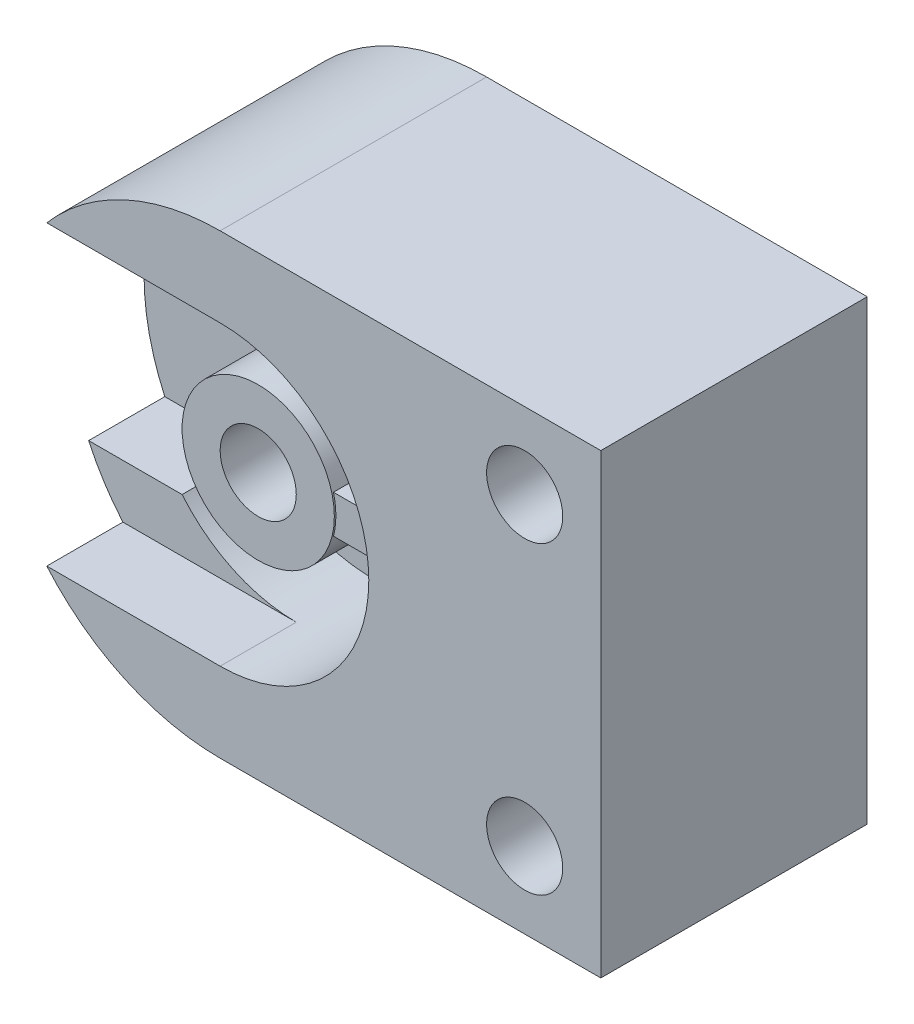
from build123d import *

# Parameters (mm, degrees)
SKETCH1_W                    = 160
SKETCH1_H                    = 120
BOSS_EXTRUDE1_DEPTH          = 70
CUT_EXTRUDE1_DEPTH           = 70
M20_TAPPED_HOLE3_D           = 17.5
M20_TAPPED_HOLE3_DEPTH       = 30
M20_TAPPED_HOLE3_CBORE_D     = 20
M20_TAPPED_HOLE3_CBORE_DEPTH = 25
M20_TAPPED_HOLE3_TIP         = 5.257530416
F_20_0MM_DOWEL_SLOT1_D       = 20
F_20_0MM_DOWEL_SLOT1_DEPTH   = 40
F_20_0MM_DOWEL_SLOT1_TIP     = 6.00860619
SKETCH16_R                   = 10
CUT_EXTRUDE3_DEPTH           = 40
CUT_EXTRUDE4_DEPTH           = 40
SKETCH18_R                   = 10
BOSS_EXTRUDE2_DEPTH          = 40
CUT_EXTRUDE6_DEPTH           = 20
SKETCH20_R                   = 10
CUT_EXTRUDE7_DEPTH           = 71
SKETCH21_R                   = 10
CUT_EXTRUDE8_DEPTH           = 20
CUT_EXTRUDE11_DEPTH          = 20
CUT_EXTRUDE12_DEPTH          = 20
SKETCH25_R                   = 20
SKETCH25_R_2                 = 10
BOSS_EXTRUDE6_DEPTH          = 10
RIB1_REACH                   = 186.662
SKETCH26_WALL_W              = 391.050063724
SKETCH26_WALL_H              = 10


with BuildPart() as part:
    # Sketch1 → Boss-Extrude1 (new body)
    with BuildSketch(Plane.XY):
        with Locations((80, 60)):
            Rectangle(SKETCH1_W, SKETCH1_H)
    extrude(amount=BOSS_EXTRUDE1_DEPTH)

    # Sketch2 → Cut-Extrude1 (cut)
    with BuildSketch(Plane.XY.offset(70)):
        with BuildLine():
            Line((60, 120), (0, 120))
            Line((0, 120), (0, 60))
            ThreePointArc((0, 60), (17.573593129, 102.426406871), (60, 120))
        make_face()
        with BuildLine():
            ThreePointArc((60, 0), (17.573593129, 17.573593129), (0, 60))
            Line((0, 60), (0, 0))
            Line((0, 0), (60, 0))
        make_face()
    extrude(amount=-CUT_EXTRUDE1_DEPTH, mode=Mode.SUBTRACT)

    # M20 Tapped Hole3
    with Locations(Plane(origin=(140, 100, 70), x_dir=(1, 0, 0), z_dir=(0, 0, 1))):
        with Locations((0, 0), (0, -80)):
            CounterBoreHole(M20_TAPPED_HOLE3_D / 2, M20_TAPPED_HOLE3_CBORE_D / 2, M20_TAPPED_HOLE3_CBORE_DEPTH, depth=M20_TAPPED_HOLE3_DEPTH)
            with Locations((0, 0, -(M20_TAPPED_HOLE3_DEPTH + M20_TAPPED_HOLE3_TIP / 2))):  # 118° drill point
                Cone(0, M20_TAPPED_HOLE3_D / 2, M20_TAPPED_HOLE3_TIP, mode=Mode.SUBTRACT)

    # 20.0mm Dowel Slot1
    with Locations(Plane.XY.offset(70)):
        with Locations((60, 60)):
            Hole(F_20_0MM_DOWEL_SLOT1_D / 2, depth=F_20_0MM_DOWEL_SLOT1_DEPTH)
            with Locations((0, 0, -(F_20_0MM_DOWEL_SLOT1_DEPTH + F_20_0MM_DOWEL_SLOT1_TIP / 2))):  # 118° drill point
                Cone(0, F_20_0MM_DOWEL_SLOT1_D / 2, F_20_0MM_DOWEL_SLOT1_TIP, mode=Mode.SUBTRACT)

    # Sketch16 → Cut-Extrude3 (cut)
    with BuildSketch(Plane.XY.offset(70)):
        with BuildLine():
            ThreePointArc((28.775010008, 35), (100, 60), (28.775010008, 85))
            Line((28.775010008, 85), (5.456439427, 85))
            ThreePointArc((5.456439427, 85), (0, 60), (5.456439427, 35))
            Line((5.456439427, 35), (28.775010008, 35))
        make_face()
        with Locations((60, 60)):
            Circle(SKETCH16_R, mode=Mode.SUBTRACT)
    extrude(amount=-CUT_EXTRUDE3_DEPTH, mode=Mode.SUBTRACT)

    # Sketch17 → Cut-Extrude4 (cut)
    with BuildSketch(Plane.XY.offset(30)):
        with BuildLine():
            Line((5.456439427, 85), (28.775010008, 85))
            ThreePointArc((28.775010008, 85), (42.679491924, 96.055512755), (60, 100))
            Line((60, 100), (15.27864045, 100))
            ThreePointArc((15.27864045, 100), (9.804072956, 92.868965731), (5.456439427, 85))
        make_face()
        with BuildLine():
            Line((28.775010008, 35), (5.456439427, 35))
            ThreePointArc((5.456439427, 35), (9.804072956, 27.131034269), (15.27864045, 20))
            Line((15.27864045, 20), (60, 20))
            ThreePointArc((60, 20), (42.679491924, 23.944487245), (28.775010008, 35))
        make_face()
    extrude(amount=CUT_EXTRUDE4_DEPTH, mode=Mode.SUBTRACT)

    # Sketch18 → Boss-Extrude2 (add)
    with BuildSketch(Plane.XY.offset(30)):
        with BuildLine():
            Line((60, 20), (15.27864045, 20))
            ThreePointArc((15.27864045, 20), (0, 60), (15.27864045, 100))
            Line((15.27864045, 100), (60, 100))
            ThreePointArc((60, 100), (100, 60), (60, 20))
        make_face()
        with Locations((60, 60)):
            Circle(SKETCH18_R, mode=Mode.SUBTRACT)
    extrude(amount=BOSS_EXTRUDE2_DEPTH)

    # Sketch19 → Cut-Extrude6 (cut)
    with BuildSketch(Plane(origin=(0, 0, 0), x_dir=(-1, 0, 0), z_dir=(0, 0, -1))):
        with BuildLine():
            ThreePointArc((-60, 99.05124838), (-43.43620227, 95.364397418), (-30, 85))
            Line((-30, 85), (-5.456439427, 85))
            ThreePointArc((-5.456439427, 85), (-9.461419592, 92.339633429), (-14.447832104, 99.05124838))
            Line((-14.447832104, 99.05124838), (-60, 99.05124838))
        make_face()
        with BuildLine():
            Line((-5.456439427, 85), (-30, 85))
            ThreePointArc((-30, 85), (-43.43620227, 95.364397418), (-60, 99.05124838))
            ThreePointArc((-60, 99.05124838), (-99.05124838, 60), (-60, 20.94875162))
            ThreePointArc((-60, 20.94875162), (-43.43620227, 24.635602582), (-30, 35))
            Line((-30, 35), (-5.456439427, 35))
            ThreePointArc((-5.456439427, 35), (0, 60), (-5.456439427, 85))
        make_face()
        with BuildLine():
            ThreePointArc((-14.447832104, 20.94875162), (-9.461419592, 27.660366571), (-5.456439427, 35))
            Line((-5.456439427, 35), (-30, 35))
            ThreePointArc((-30, 35), (-43.43620227, 24.635602582), (-60, 20.94875162))
            Line((-60, 20.94875162), (-14.447832104, 20.94875162))
        make_face()
    extrude(amount=-CUT_EXTRUDE6_DEPTH, mode=Mode.SUBTRACT)

    # Sketch20 → Cut-Extrude7 (cut)
    with BuildSketch(Plane.XY.offset(70)):
        with Locations(Location((60, 60, 0), (0, 0, 180))):
            Circle(SKETCH20_R)
    extrude(amount=-CUT_EXTRUDE7_DEPTH, mode=Mode.SUBTRACT)

    # Sketch21 → Cut-Extrude8 (cut)
    with BuildSketch(Plane.XY.offset(70)):
        with BuildLine():
            Line((30, 35), (5.456439427, 35))
            ThreePointArc((5.456439427, 35), (9.461419592, 27.660366571), (14.447832104, 20.94875162))
            Line((14.447832104, 20.94875162), (60, 20.94875162))
            ThreePointArc((60, 20.94875162), (43.43620227, 24.635602582), (30, 35))
        make_face()
        with BuildLine():
            Line((5.456439427, 85), (30, 85))
            ThreePointArc((30, 85), (43.43620227, 95.364397418), (60, 99.05124838))
            Line((60, 99.05124838), (14.447832104, 99.05124838))
            ThreePointArc((14.447832104, 99.05124838), (9.461419592, 92.339633429), (5.456439427, 85))
        make_face()
        with BuildLine():
            ThreePointArc((60, 99.05124838), (43.43620227, 95.364397418), (30, 85))
            Line((30, 85), (5.456439427, 85))
            ThreePointArc((5.456439427, 85), (0, 60), (5.456439427, 35))
            Line((5.456439427, 35), (30, 35))
            ThreePointArc((30, 35), (43.43620227, 24.635602582), (60, 20.94875162))
            ThreePointArc((60, 20.94875162), (99.05124838, 60), (60, 99.05124838))
        make_face()
        with Locations(Location((60, 60, 0), (0, 0, 180))):
            Circle(SKETCH21_R, mode=Mode.SUBTRACT)
    extrude(amount=-CUT_EXTRUDE8_DEPTH, mode=Mode.SUBTRACT)

    # Sketch22 → Cut-Extrude11 (cut)
    with BuildSketch(Plane.XY.offset(50)):
        with BuildLine():
            ThreePointArc((60, 99.05124838), (43.43620227, 95.364397418), (30, 85))
            Line((30, 85), (5.456439427, 85))
            ThreePointArc((5.456439427, 85), (4.387727415, 82.522769322), (3.431457505, 80))
            Line((3.431457505, 80), (60, 80))
            ThreePointArc((60, 80), (74.142135624, 74.142135624), (80, 60))
            ThreePointArc((80, 60), (74.142135624, 45.857864376), (60, 40))
            Line((60, 40), (3.431457505, 40))
            ThreePointArc((3.431457505, 40), (4.387727415, 37.477230678), (5.456439427, 35))
            Line((5.456439427, 35), (30, 35))
            ThreePointArc((30, 35), (43.43620227, 24.635602582), (60, 20.94875162))
            ThreePointArc((60, 20.94875162), (99.05124838, 60), (60, 99.05124838))
        make_face()
    extrude(amount=-CUT_EXTRUDE11_DEPTH, mode=Mode.SUBTRACT)

    # Sketch23 → Cut-Extrude12 (cut)
    with BuildSketch(Plane.XY.offset(50)):
        with BuildLine():
            ThreePointArc((60, 40), (40, 60), (60, 80))
            Line((60, 80), (3.431457505, 80))
            ThreePointArc((3.431457505, 80), (0, 60), (3.431457505, 40))
            Line((3.431457505, 40), (60, 40))
        make_face()
    extrude(amount=-CUT_EXTRUDE12_DEPTH, mode=Mode.SUBTRACT)

    # Sketch25 → Boss-Extrude6 (add)
    with BuildSketch(Plane.XY.offset(50)):
        with Locations((60, 60)):
            Circle(SKETCH25_R)
        with Locations(Location((60, 60, 0), (0, 0, 180))):
            Circle(SKETCH25_R_2, mode=Mode.SUBTRACT)
    extrude(amount=BOSS_EXTRUDE6_DEPTH)

    # Sketch26 wall → Rib1 (add, up to next)
    with BuildSketch(Plane(origin=(89.34113782, 60, 59.598387785), x_dir=(1, 0, 0), z_dir=(0, 0, -1)), mode=Mode.PRIVATE) as rib1_sk1:
        Rectangle(SKETCH26_WALL_W, SKETCH26_WALL_H)
    rib1_tool1 = extrude(rib1_sk1.sketch, amount=RIB1_REACH, mode=Mode.PRIVATE) - part.part
    add(rib1_tool1.solids().sort_by_distance((89.34113782, 60, 59.598387785))[0])


solid = part.part
